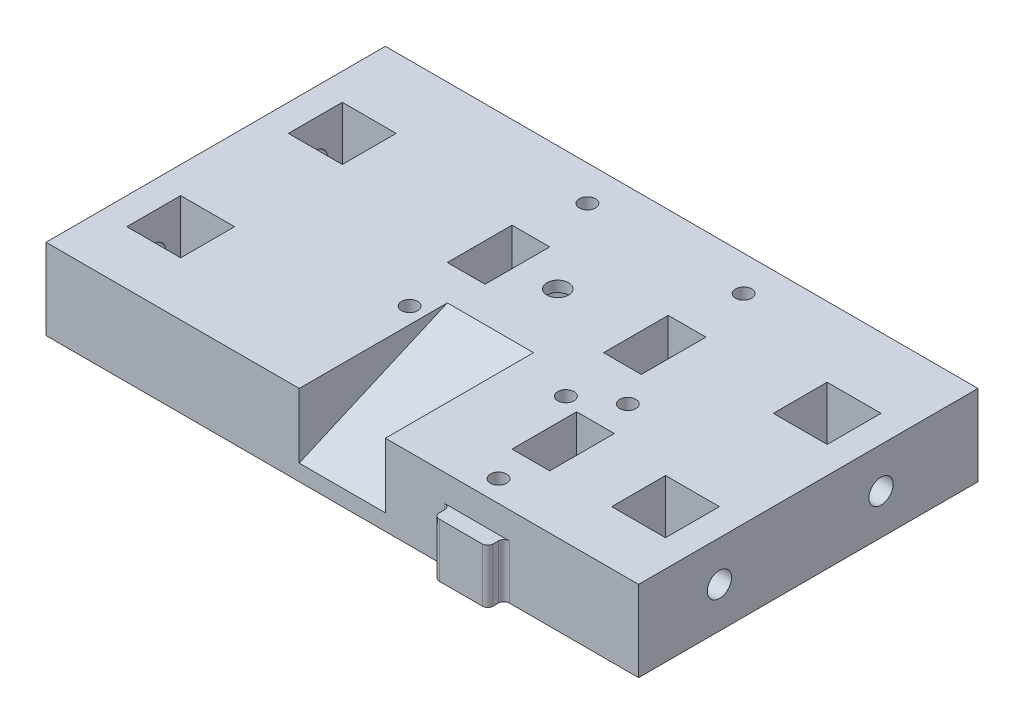
from build123d import *

# Parameters (mm, degrees)
CROQUIS1_W              = 80
CROQUIS1_H              = 60
CROQUIS1_R              = 1.5
CROQUIS1_W_2            = 7
CROQUIS1_H_2            = 25
CROQUIS1_W_3            = 10
CROQUIS1_H_3            = 20
CROQUIS1_H_4            = 10
CROQUIS1_W_4            = 5
CROQUIS1_H_5            = 6.5
SALIENTE_EXTRUIR1_DEPTH = 15
CORTAR_EXTRUIR1_DEPTH   = 5
CROQUIS3_R              = 1.5
CORTAR_EXTRUIR2_DEPTH   = 25
CROQUIS6_R              = 1.5
CORTAR_EXTRUIR3_DEPTH   = 25
CROQUIS8_W              = 15
CROQUIS8_H              = 17.838651154
CROQUIS8_R              = 2
SALIENTE_EXTRUIR2_DEPTH = 2
CORTAR_EXTRUIR4_START   = -55
CORTAR_EXTRUIR4_DEPTH   = 8
CROQUIS10_R             = 1.5
CROQUIS10_W             = 7
CROQUIS10_H             = 12
CORTAR_EXTRUIR5_DEPTH   = 16
CROQUIS12_W             = 110
CROQUIS12_H             = 15
SALIENTE_EXTRUIR3_DEPTH = 3
CORTAR_EXTRUIR6_DEPTH   = 5
SALIENTE_EXTRUIR4_DEPTH = 10
CROQUIS15_R             = 2.25
CORTAR_EXTRUIR7_DEPTH   = 10
CROQUIS16_R             = 2.25
CORTAR_EXTRUIR8_DEPTH   = 10


with BuildPart() as part:
    # Croquis1 → Saliente-Extruir1 (new body)
    with BuildSketch(Plane(origin=(0, 0, 0), x_dir=(1, 0, 0), z_dir=(0, 1, 0))):
        with Locations((0, -10)):
            Rectangle(CROQUIS1_W, CROQUIS1_H)
        with Locations(Location((18, -16.5, 0), (0, 0, 270))):
            Circle(CROQUIS1_R, mode=Mode.SUBTRACT)
        with Locations(Location((-11, -16.5, 0), (0, 0, 270))):
            Circle(CROQUIS1_R, mode=Mode.SUBTRACT)
        with Locations(Location((18, 16.5, 0), (0, 0, 270))):
            Circle(CROQUIS1_R, mode=Mode.SUBTRACT)
        with Locations(Location((-11, 16.5, 0), (0, 0, 270))):
            Circle(CROQUIS1_R, mode=Mode.SUBTRACT)
        with Locations((18, 0)):
            Rectangle(CROQUIS1_W_2, CROQUIS1_H_2, mode=Mode.SUBTRACT)
        Polygon((6.495190528, 3.75), (0, 7.5), (-6.495190528, 3.75), (-6.495190528, -3.75), (0, -7.5), (6.495190528, -3.75), align=None, mode=Mode.SUBTRACT)
        with Locations((-11, 0)):
            Rectangle(CROQUIS1_W_2, CROQUIS1_H_2, mode=Mode.SUBTRACT)
        with Locations((-45, -10)):
            Rectangle(CROQUIS1_W_3, CROQUIS1_H_3)
        with Locations((-45, -35)):
            Rectangle(CROQUIS1_W_3, CROQUIS1_H_4)
        with Locations((-52.5, -10)):
            Rectangle(CROQUIS1_W_4, CROQUIS1_H)
        with Locations((-45, 15)):
            Rectangle(CROQUIS1_W_3, CROQUIS1_H_4)
        with Locations((45, 15)):
            Rectangle(CROQUIS1_W_3, CROQUIS1_H_4)
        with Locations((52.5, -10)):
            Rectangle(CROQUIS1_W_4, CROQUIS1_H)
        with Locations((45, -10)):
            Rectangle(CROQUIS1_W_3, CROQUIS1_H_3)
        with Locations((45, -35)):
            Rectangle(CROQUIS1_W_3, CROQUIS1_H_4)
        with Locations((-11, 9.25)):
            Rectangle(CROQUIS1_W_2, CROQUIS1_H_5)
        with Locations((-11, -9.25)):
            Rectangle(CROQUIS1_W_2, CROQUIS1_H_5)
        with Locations((18, 9.25)):
            Rectangle(CROQUIS1_W_2, CROQUIS1_H_5)
        with Locations((18, -9.25)):
            Rectangle(CROQUIS1_W_2, CROQUIS1_H_5)
    extrude(amount=SALIENTE_EXTRUIR1_DEPTH)

    # Croquis2 → Cortar-Extruir1 (cut)
    with BuildSketch(Plane.XZ):
        Polygon((-6.958548116, 16.5), (-8.979274058, 20), (-13.020725942, 20), (-15.041451884, 16.5), (-13.020725942, 13), (-8.979274058, 13), align=None)
        Polygon((22.041451884, 16.5), (20.020725942, 20), (15.979274058, 20), (13.958548116, 16.5), (15.979274058, 13), (20.020725942, 13), align=None)
        Polygon((-6.958548116, -16.5), (-8.979274058, -13), (-13.020725942, -13), (-15.041451884, -16.5), (-13.020725942, -20), (-8.979274058, -20), align=None)
        Polygon((22.041451884, -16.5), (20.020725942, -13), (15.979274058, -13), (13.958548116, -16.5), (15.979274058, -20), (20.020725942, -20), align=None)
    extrude(amount=-CORTAR_EXTRUIR1_DEPTH, mode=Mode.SUBTRACT)

    # Croquis3 → Cortar-Extruir2 (cut)
    with BuildSketch(Plane(origin=(55, 0, 0), x_dir=(0, 0, -1), z_dir=(1, 0, 0))):
        with Locations((-25, 7.5)):
            Circle(CROQUIS3_R)
        with Locations((5, 7.5)):
            Circle(CROQUIS3_R)
    extrude(amount=-CORTAR_EXTRUIR2_DEPTH, mode=Mode.SUBTRACT)

    # Croquis6 → Cortar-Extruir3 (cut)
    with BuildSketch(Plane.ZY.offset(55)):
        with Locations(Location((-5, 7.5, 0), (0, 0, 180))):
            Circle(CROQUIS6_R)
        with Locations(Location((25, 7.5, 0), (0, 0, 180))):
            Circle(CROQUIS6_R)
    extrude(amount=-CORTAR_EXTRUIR3_DEPTH, mode=Mode.SUBTRACT)

    # Croquis8 → Saliente-Extruir2 (add)
    with BuildSketch(Plane(origin=(0, 15, 0), x_dir=(1, 0, 0), z_dir=(0, 1, 0))):
        Rectangle(CROQUIS8_W, CROQUIS8_H)
        with Locations(Location((0, 0, 0), (0, 0, 270))):
            Circle(CROQUIS8_R, mode=Mode.SUBTRACT)
    extrude(amount=-SALIENTE_EXTRUIR2_DEPTH)

    # Croquis9 → Cortar-Extruir4 (cut, symmetric)
    with BuildSketch(Plane(origin=(55, 0, 0), x_dir=(0, 0, -1), z_dir=(1, 0, 0)).offset(CORTAR_EXTRUIR4_START)):
        Polygon((-40, 3), (-12.5, 15), (-40, 15), align=None)
    extrude(amount=CORTAR_EXTRUIR4_DEPTH, both=True, mode=Mode.SUBTRACT)

    # Croquis10 → Cortar-Extruir5 (cut)
    with BuildSketch(Plane(origin=(0, 15, 0), x_dir=(1, 0, 0), z_dir=(0, 1, 0))):
        with Locations(Location((25, -12, 0), (0, 0, 270))):
            Circle(CROQUIS10_R)
        with Locations(Location((25, -36, 0), (0, 0, 270))):
            Circle(CROQUIS10_R)
        with Locations((25, -24)):
            Rectangle(CROQUIS10_W, CROQUIS10_H)
    extrude(amount=-CORTAR_EXTRUIR5_DEPTH, mode=Mode.SUBTRACT)

    # Croquis12 → Saliente-Extruir3 (add)
    with BuildSketch(Plane(origin=(0, 0, -20), x_dir=(-1, 0, 0), z_dir=(0, 0, -1))):
        with Locations((0, 7.5)):
            Rectangle(CROQUIS12_W, CROQUIS12_H)
    extrude(amount=SALIENTE_EXTRUIR3_DEPTH)

    # Croquis13 → Cortar-Extruir6 (cut)
    with BuildSketch(Plane.XZ):
        Polygon((29.041451884, 12), (27.020725942, 15.5), (22.979274058, 15.5), (20.958548116, 12), (22.979274058, 8.5), (27.020725942, 8.5), align=None)
        Polygon((29.041451884, 36), (27.020725942, 39.5), (22.979274058, 39.5), (20.958548116, 36), (22.979274058, 32.5), (27.020725942, 32.5), align=None)
    extrude(amount=-CORTAR_EXTRUIR6_DEPTH, mode=Mode.SUBTRACT)

    # Croquis14 → Saliente-Extruir4 (add)
    with BuildSketch(Plane.XZ):
        with BuildLine():
            Line((30, 41), (30, 42))
            ThreePointArc((30, 42), (29.707106781, 42.707106781), (29, 43))
            Line((29, 43), (21, 43))
            ThreePointArc((21, 43), (20.292893219, 42.707106781), (20, 42))
            Line((20, 42), (20, 41))
            ThreePointArc((20, 41), (19.707106781, 40.292893219), (19, 40))
            Line((19, 40), (31, 40))
            ThreePointArc((31, 40), (30.292893219, 40.292893219), (30, 41))
        make_face()
    extrude(amount=-SALIENTE_EXTRUIR4_DEPTH)

    # Croquis15 → Cortar-Extruir7 (cut)
    with BuildSketch(Plane(origin=(55, 0, 0), x_dir=(0, 0, -1), z_dir=(1, 0, 0))):
        with Locations((-25, 7.5)):
            Circle(CROQUIS15_R)
        with Locations((5, 7.5)):
            Circle(CROQUIS15_R)
    extrude(amount=-CORTAR_EXTRUIR7_DEPTH, mode=Mode.SUBTRACT)

    # Croquis16 → Cortar-Extruir8 (cut)
    with BuildSketch(Plane.ZY.offset(55)):
        with Locations(Location((-5, 7.5, 0), (0, 0, 180))):
            Circle(CROQUIS16_R)
        with Locations(Location((25, 7.5, 0), (0, 0, 180))):
            Circle(CROQUIS16_R)
    extrude(amount=-CORTAR_EXTRUIR8_DEPTH, mode=Mode.SUBTRACT)


solid = part.part
